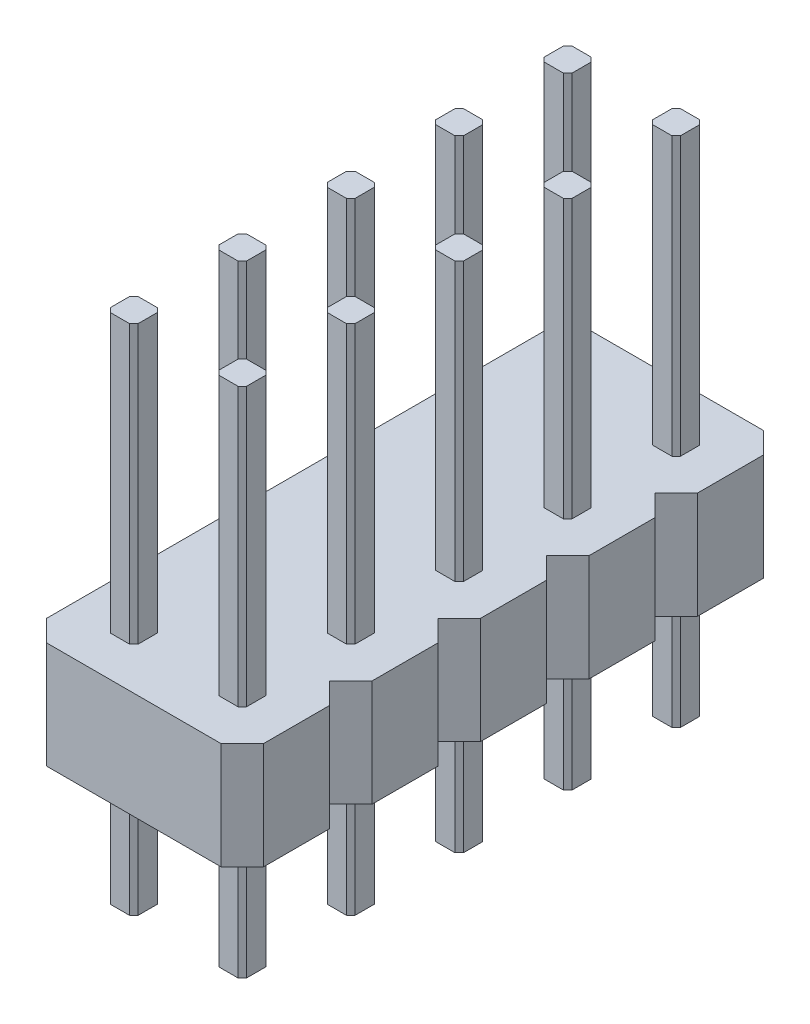
from build123d import *

# Parameters (mm, degrees)
BOSS_EXTRUDE1_DEPTH = 12
LPATTERN1_COUNT     = 2
LPATTERN1_PITCH     = 2.54
BOSS_EXTRUDE2_DEPTH = 2.5
LPATTERN2_COUNT     = 5
LPATTERN2_PITCH     = 2.54


with BuildPart() as part:
    # Sketch1 → Boss-Extrude1 (new body)
    with BuildSketch(Plane(origin=(0, 0, 0), x_dir=(1, 0, 0), z_dir=(0, 1, 0))):
        Polygon((-0.225, -0.325), (-0.325, -0.225), (-0.325, 0.225), (-0.225, 0.325), (0.225, 0.325), (0.325, 0.225), (0.325, -0.225), (0.225, -0.325), align=None)
    extrude(amount=BOSS_EXTRUDE1_DEPTH)


with BuildPart() as lpattern1_1:
    # LPattern1: pattern copy
    add(part.part.moved(Location(Vector(1, 0, 0) * (1 * LPATTERN1_PITCH))))


with BuildPart() as part_1:
    add(part.part)

    add(lpattern1_1.part)  # Boss-Extrude2 merges LPattern1_1
    # Sketch2 → Boss-Extrude2 (add)
    with BuildSketch(Plane(origin=(0, 3, 0), x_dir=(-1, 0, 0), z_dir=(0, -1, 0))):
        Polygon((-3.81, 0.77), (-3.31, 1.27), (0.77, 1.27), (1.27, 0.77), (1.27, -0.77), (0.77, -1.27), (-3.31, -1.27), (-3.81, -0.77), align=None)
    extrude(amount=-BOSS_EXTRUDE2_DEPTH)


with BuildPart() as lpattern2_1:
    # LPattern2: pattern copy
    add(part_1.part.moved(Location(Vector(0, 0, 1) * (1 * LPATTERN2_PITCH))))


with BuildPart() as lpattern2_2:
    # LPattern2: pattern copy
    add(part_1.part.moved(Location(Vector(0, 0, 1) * (2 * LPATTERN2_PITCH))))


with BuildPart() as lpattern2_3:
    # LPattern2: pattern copy
    add(part_1.part.moved(Location(Vector(0, 0, 1) * (3 * LPATTERN2_PITCH))))


with BuildPart() as lpattern2_4:
    # LPattern2: pattern copy
    add(part_1.part.moved(Location(Vector(0, 0, 1) * (4 * LPATTERN2_PITCH))))


with BuildPart() as lpattern2_2_1:
    add(lpattern2_2.part)

    # Combine1: union LPattern2_1, LPattern2_3, part, LPattern2_4
    add(lpattern2_1.part)
    add(lpattern2_3.part)
    add(part_1.part)
    add(lpattern2_4.part)


solid = lpattern2_2_1.part
